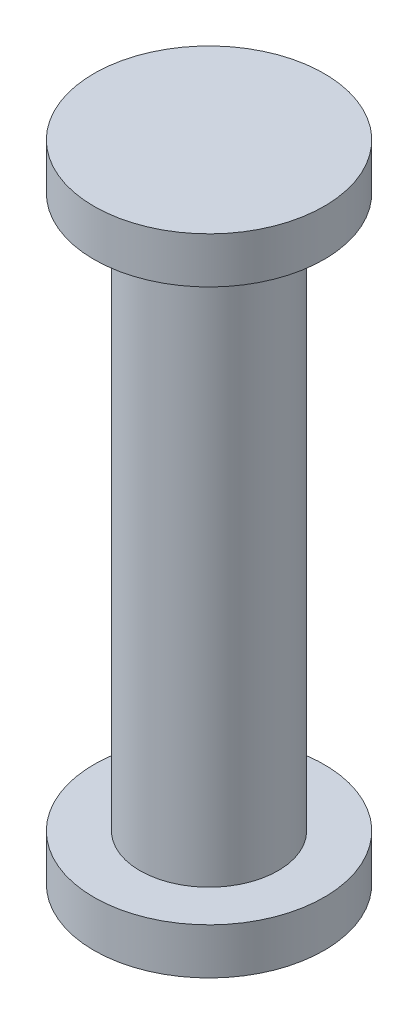
from build123d import *

# Parameters (mm, degrees)
SKETCH1_R           = 2.5
BOSS_EXTRUDE1_DEPTH = 1
SKETCH2_R           = 1.5
BOSS_EXTRUDE2_DEPTH = 12
SKETCH3_R           = 2.5
BOSS_EXTRUDE3_DEPTH = 1


with BuildPart() as part:
    # Sketch1 → Boss-Extrude1 (new body)
    with BuildSketch(Plane(origin=(0, 0, 0), x_dir=(1, 0, 0), z_dir=(0, 1, 0))):
        Circle(SKETCH1_R)
    extrude(amount=BOSS_EXTRUDE1_DEPTH)

    # Sketch2 → Boss-Extrude2 (add)
    with BuildSketch(Plane(origin=(0, 1, 0), x_dir=(1, 0, 0), z_dir=(0, 1, 0))):
        Circle(SKETCH2_R)
    extrude(amount=BOSS_EXTRUDE2_DEPTH)

    # Sketch3 → Boss-Extrude3 (add)
    with BuildSketch(Plane(origin=(0, 13, 0), x_dir=(1, 0, 0), z_dir=(0, 1, 0))):
        Circle(SKETCH3_R)
    extrude(amount=BOSS_EXTRUDE3_DEPTH)


solid = part.part
